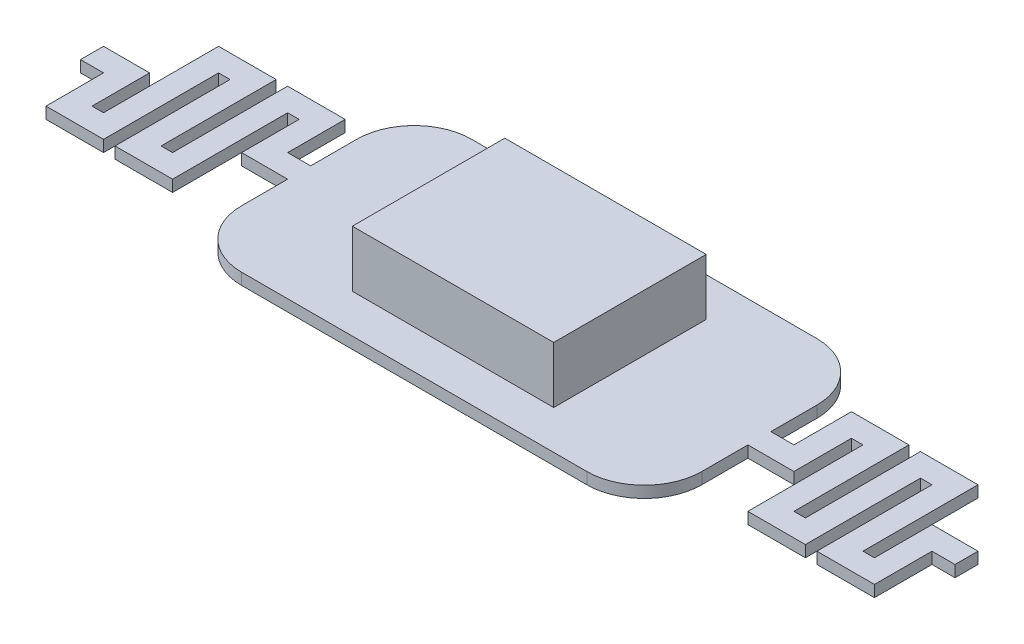
from build123d import *

# Parameters (mm, degrees)
SKETCH1_W           = 8
SKETCH1_H           = 4
BOSS_EXTRUDE1_DEPTH = 0.2
FILLET1_R           = 1
BOSS_EXTRUDE2_DEPTH = 0.2
SKETCH3_W           = 3.5
SKETCH3_H           = 2.65
BOSS_EXTRUDE3_DEPTH = 0.98


with BuildPart() as part:
    # Sketch1 → Boss-Extrude1 (new body)
    with BuildSketch(Plane(origin=(0, 0, 0), x_dir=(1, 0, 0), z_dir=(0, 1, 0))):
        Rectangle(SKETCH1_W, SKETCH1_H)
    extrude(amount=BOSS_EXTRUDE1_DEPTH)

    # Fillet1
    fillet1_edges = [part.edges().sort_by_distance(p)[0] for p in [
        (4, 0.1, 2),
        (-4, 0.1, 2),
        (-4, 0.1, -2),
        (4, 0.1, -2),
    ]]
    fillet(fillet1_edges, radius=FILLET1_R)

    # Sketch2 → Boss-Extrude2 (add)
    with BuildSketch(Plane(origin=(0, 0.2, 0), x_dir=(1, 0, 0), z_dir=(0, 1, 0))):
        Polygon((4, 0.2), (4, 0), (4.6, 0), (4.6, 1), (5.2, 1), (5.2, -1), (5.8, -1), (5.8, 1), (6.4, 1), (6.4, -1), (7, -1), (7, 0), (7.6, 0), (7.6, 0.2), (6.8, 0.2), (6.8, -0.8), (6.6, -0.8), (6.6, 1.2), (5.6, 1.2), (5.6, -0.8), (5.4, -0.8), (5.4, 1.2), (4.4, 1.2), (4.4, 0.2), align=None)
        Polygon((4.6, 0), (4, 0), (4, -0.2), (4.8, -0.2), (4.8, 0.8), (5, 0.8), (5, -1.2), (6, -1.2), (6, 0.8), (6.2, 0.8), (6.2, -1.2), (7.2, -1.2), (7.2, -0.2), (7.6, -0.2), (7.6, 0), (7, 0), (7, -1), (6.4, -1), (6.4, 1), (5.8, 1), (5.8, -1), (5.2, -1), (5.2, 1), (4.6, 1), align=None)
    boss_extrude2 = extrude(amount=-BOSS_EXTRUDE2_DEPTH)

    # Mirror1: Boss-Extrude2 across plane
    add(boss_extrude2.mirror(Plane(origin=(0, 0, 0), x_dir=(0, 0, 1), z_dir=(1, 0, 0))))

    # Sketch3 → Boss-Extrude3 (add)
    with BuildSketch(Plane(origin=(0, 0.2, 0), x_dir=(1, 0, 0), z_dir=(0, 1, 0))):
        Rectangle(SKETCH3_W, SKETCH3_H)
    extrude(amount=BOSS_EXTRUDE3_DEPTH)


solid = part.part
